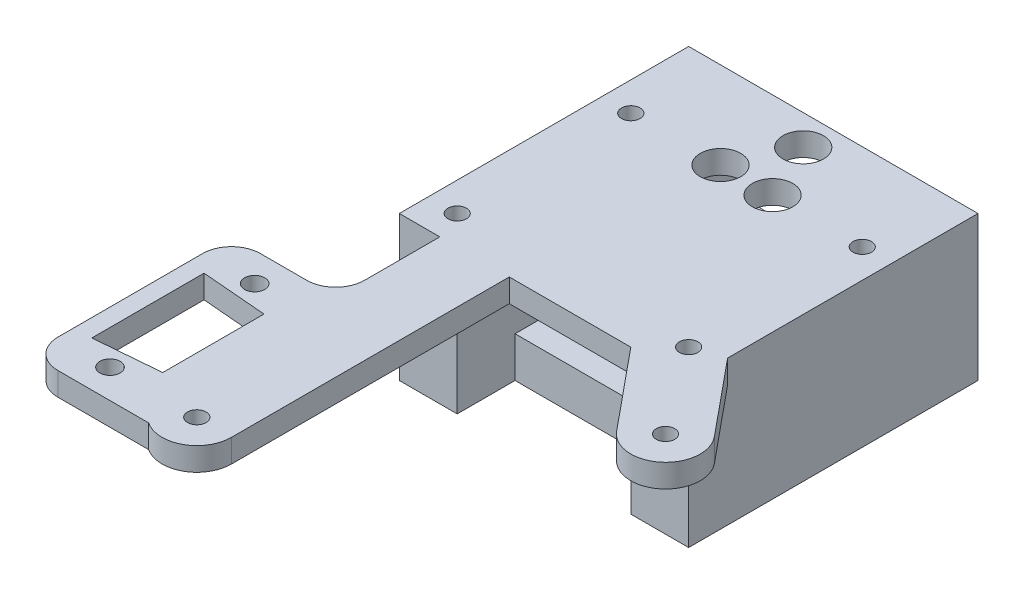
from build123d import *

# Parameters (mm, degrees)
RESSALTO_EXTRUS_O1_DEPTH = 50
ESBO_O2_R                = 1.6
CORTE_EXTRUS_O1_DEPTH    = 40
ESBO_O3_R                = 1.6
ESBO_O3_R_2              = 1.75
ESBO_O3_R_3              = 3.5
RESSALTO_EXTRUS_O2_DEPTH = 4
ESBO_O4_W                = 30
ESBO_O4_H                = 10
CORTE_EXTRUS_O2_DEPTH    = 7
FILETE1_R                = 5
CORTE_EXTRUS_O3_START    = -18
ESBO_O5_R                = 3
CORTE_EXTRUS_O3_DEPTH    = 3


with BuildPart() as part:
    # Esboço1 → Ressalto-extrusão1 (new body)
    with BuildSketch(Plane.XY):
        Polygon((-25, 0), (-15, 0), (-15, -14), (15, -14), (15, 0), (25, 0), (25, -21), (-25, -21), align=None)
    extrude(amount=RESSALTO_EXTRUS_O1_DEPTH)

    # Esboço2 → Corte-extrusão1 (cut)
    with BuildSketch(Plane.XZ.offset(21)):
        with Locations((-20, 45)):
            Circle(ESBO_O2_R)
        with Locations((20, 45)):
            Circle(ESBO_O2_R)
        with Locations((20, 15)):
            Circle(ESBO_O2_R)
        with Locations((-20, 15)):
            Circle(ESBO_O2_R)
        with Locations((-4.5, 15)):
            Circle(ESBO_O2_R)
        with Locations((0, 5.2)):
            Circle(ESBO_O2_R)
        with Locations((4.5, 15)):
            Circle(ESBO_O2_R)
    extrude(amount=-CORTE_EXTRUS_O1_DEPTH, mode=Mode.SUBTRACT)

    # Esboço3 → Ressalto-extrusão2 (add)
    with BuildSketch(Plane(origin=(0, 0, 0), x_dir=(1, 0, 0), z_dir=(0, 1, 0))):
        with BuildLine():
            Line((25, -43.266873708), (35.632900644, -56.18735897))
            ThreePointArc((35.632900644, -56.18735897), (34.81264103, -64.632900644), (26.367099356, -63.81264103))
            Line((26.367099356, -63.81264103), (15, -50))
            Line((15, -50), (-6, -50))
            Line((-6, -50), (-6, -98))
            ThreePointArc((-6, -98), (-9.162725669, -103.286764074), (-15.31662479, -103))
            Line((-15.31662479, -103), (-36, -103))
            Line((-36, -103), (-36, -68))
            Line((-36, -68), (-18, -68))
            Line((-18, -68), (-18, -50))
            Line((-18, -50), (-25, -50))
            Line((-25, -50), (-25, 0))
            Line((-25, 0), (25, 0))
            Line((25, 0), (25, -43.266873708))
        make_face()
        with Locations((20, -45)):
            Circle(ESBO_O3_R, mode=Mode.SUBTRACT)
        with Locations((20, -15)):
            Circle(ESBO_O3_R, mode=Mode.SUBTRACT)
        with Locations((-20, -15)):
            Circle(ESBO_O3_R, mode=Mode.SUBTRACT)
        with Locations((-20, -45)):
            Circle(ESBO_O3_R, mode=Mode.SUBTRACT)
        with Locations((31, -60)):
            Circle(ESBO_O3_R, mode=Mode.SUBTRACT)
        with Locations((-12, -98)):
            Circle(ESBO_O3_R, mode=Mode.SUBTRACT)
        with Locations((-27, -98)):
            Circle(ESBO_O3_R_2, mode=Mode.SUBTRACT)
        with Locations((-27, -73)):
            Circle(ESBO_O3_R_2, mode=Mode.SUBTRACT)
        with Locations((0, -5.2)):
            Circle(ESBO_O3_R_3, mode=Mode.SUBTRACT)
        with Locations((-4.5, -15)):
            Circle(ESBO_O3_R_3, mode=Mode.SUBTRACT)
        with Locations((4.5, -15)):
            Circle(ESBO_O3_R_3, mode=Mode.SUBTRACT)
        Polygon((-32.940921409, -75.8), (-21.640921409, -76.75), (-21.640921409, -94.25), (-32.940921409, -95.2), align=None, mode=Mode.SUBTRACT)
    extrude(amount=RESSALTO_EXTRUS_O2_DEPTH)

    # Esboço4 → Corte-extrusão2 (cut)
    with BuildSketch(Plane.XZ.offset(21)):
        with Locations((0, 45)):
            Rectangle(ESBO_O4_W, ESBO_O4_H)
    extrude(amount=-CORTE_EXTRUS_O2_DEPTH, mode=Mode.SUBTRACT)

    # Filete1
    filete1_edges = [part.edges().sort_by_distance(p)[0] for p in [
        (-18, 2, 68),
        (-36, 2, 68),
        (-36, 2, 103),
    ]]
    fillet(filete1_edges, radius=FILETE1_R)

    # Esboço5 → Corte-extrusão3 (cut)
    with BuildSketch(Plane(origin=(0, 4, 0), x_dir=(1, 0, 0), z_dir=(0, 1, 0)).offset(CORTE_EXTRUS_O3_START)):
        with Locations((4.5, -15)):
            Circle(ESBO_O5_R)
        with Locations((-4.5, -15)):
            Circle(ESBO_O5_R)
        with Locations((0, -5.2)):
            Circle(ESBO_O5_R)
    extrude(amount=-CORTE_EXTRUS_O3_DEPTH, mode=Mode.SUBTRACT)


solid = part.part
